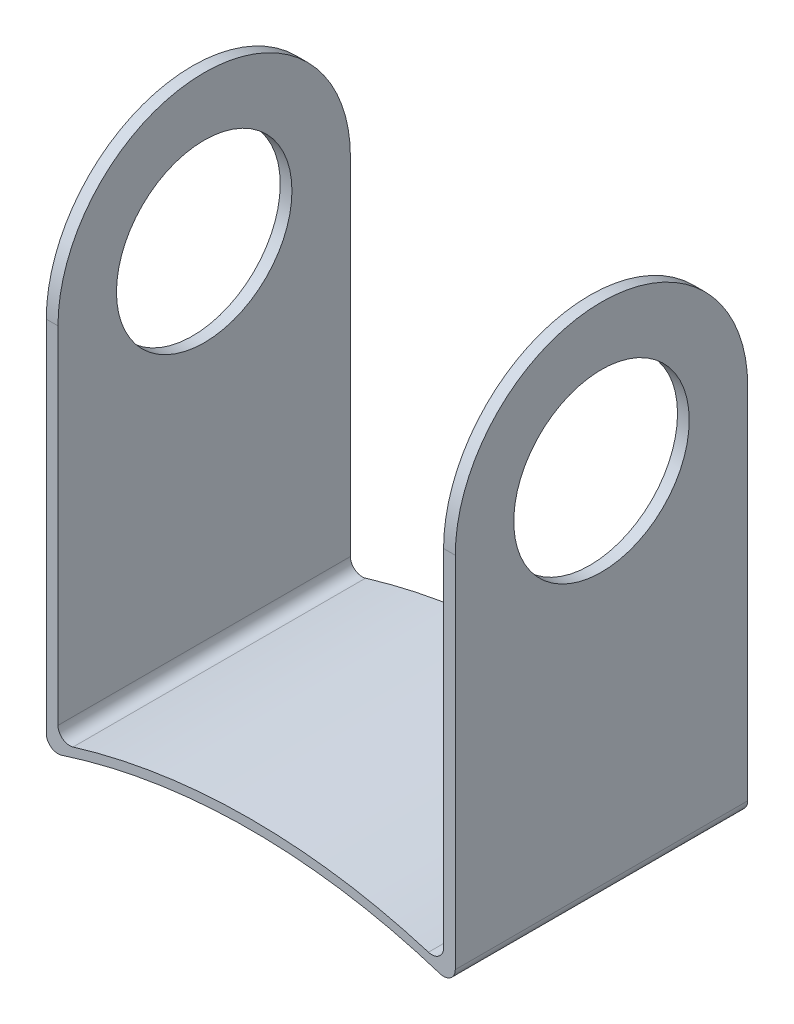
from build123d import *

# Parameters (mm, degrees)
BOSS_EXTRUDE1_DEPTH = 25
FILLET1_R           = 1
FILLET2_R           = 1
FILLET3_R           = 0.05
CUT_EXTRUDE1_DEPTH  = 66.934416438
SKETCH5_R           = 7.5
CUT_EXTRUDE2_DEPTH  = 66.193638666


with BuildPart() as part:
    # Sketch2 → Boss-Extrude1 (new body)
    with BuildSketch(Plane.XY):
        with BuildLine():
            Line((-5.6909785, 5.576436412), (-5.6909785, 50))
            Line((-5.6909785, 50), (-6.6909785, 50))
            Line((-6.6909785, 50), (-6.6909785, 4.44447901))
            ThreePointArc((-6.6909785, 4.44447901), (10.790063167, 7.449269771), (28.271104834, 4.44447901))
            Line((28.271104834, 4.44447901), (28.271104834, 49.569009084))
            Line((28.271104834, 49.569009084), (27.271104834, 49.569009084))
            Line((27.271104834, 49.569009084), (27.271104834, 5.576436412))
            ThreePointArc((27.271104834, 5.576436412), (10.790063167, 8.24907617), (-5.6909785, 5.576436412))
        make_face()
    extrude(amount=BOSS_EXTRUDE1_DEPTH)

    # Fillet1
    fillet1_edges = [part.edges().sort_by_distance(p)[0] for p in [
        (-6.6909785, 4.44447901, 12.5),
        (28.271104834, 4.44447901, 12.5),
    ]]
    fillet(fillet1_edges, radius=FILLET1_R)

    # Fillet2
    fillet2_edges = [part.edges().sort_by_distance(p)[0] for p in [
        (-5.6909785, 5.576436412, 12.5),
        (27.271104834, 5.576436412, 12.5),
    ]]
    fillet(fillet2_edges, radius=FILLET2_R)

    # Fillet3
    fillet3_edges = [part.edges().sort_by_distance(p)[0] for p in [
        (-5.6909785, 50, 12.5),
        (-6.6909785, 50, 12.5),
        (28.271104834, 49.569009084, 12.5),
        (27.271104834, 49.569009084, 12.5),
    ]]
    fillet(fillet3_edges, radius=FILLET3_R)

    # Sketch4 → Cut-Extrude1 (cut, through all)
    with BuildSketch(Plane(origin=(28.271104834, 0, 0), x_dir=(0, 0, -1), z_dir=(1, 0, 0))):
        with BuildLine():
            Line((-25, 36.519009084), (-25, 49.519009084))
            Line((-25, 49.519009084), (0, 49.519009084))
            Line((0, 49.519009084), (0, 36.519009084))
            ThreePointArc((0, 36.519009084), (-12.5, 49.019009084), (-25, 36.519009084))
        make_face()
    extrude(amount=-CUT_EXTRUDE1_DEPTH, mode=Mode.SUBTRACT)


with BuildPart() as body_2:
    # of the pieces the cut leaves, the one that is kept (cut_extrude1_keep)
    add(part.part.solids().sort_by_distance((-5.6909785, 6.944623545, 0))[0])

    # Sketch5 → Cut-Extrude2 (cut, through all)
    with BuildSketch(Plane(origin=(28.271104834, 0, 0), x_dir=(0, 0, -1), z_dir=(1, 0, 0))):
        with Locations((-12.5, 36.519009084)):
            Circle(SKETCH5_R)
    extrude(amount=-CUT_EXTRUDE2_DEPTH, mode=Mode.SUBTRACT)


solid = body_2.part
